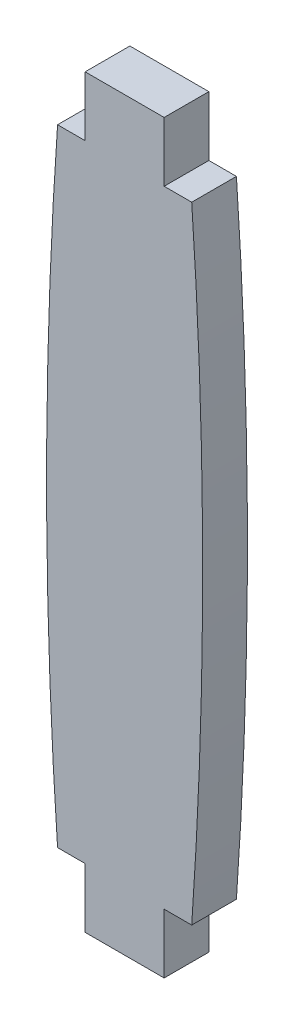
from build123d import *

# Parameters (mm, degrees)
SALIENTE_EXTRUIR1_DEPTH = 3


with BuildPart() as part:
    # Croquis1 → Saliente-Extruir1 (new body)
    with BuildSketch(Plane.XY):
        with BuildLine():
            Line((0, 0), (1.85, 0))
            Line((1.85, 0), (1.85, -4))
            Line((1.85, -4), (7.15, -4))
            Line((7.15, -4), (7.15, 0))
            Line((7.15, 0), (9, 0))
            ThreePointArc((9, 0), (9.735902588, 21), (9, 42))
            Line((9, 42), (7.15, 42))
            Line((7.15, 42), (7.15, 46))
            Line((7.15, 46), (1.85, 46))
            Line((1.85, 46), (1.85, 42))
            Line((1.85, 42), (0, 42))
            ThreePointArc((0, 42), (-0.735902588, 21), (0, 0))
        make_face()
    extrude(amount=SALIENTE_EXTRUIR1_DEPTH)


solid = part.part
